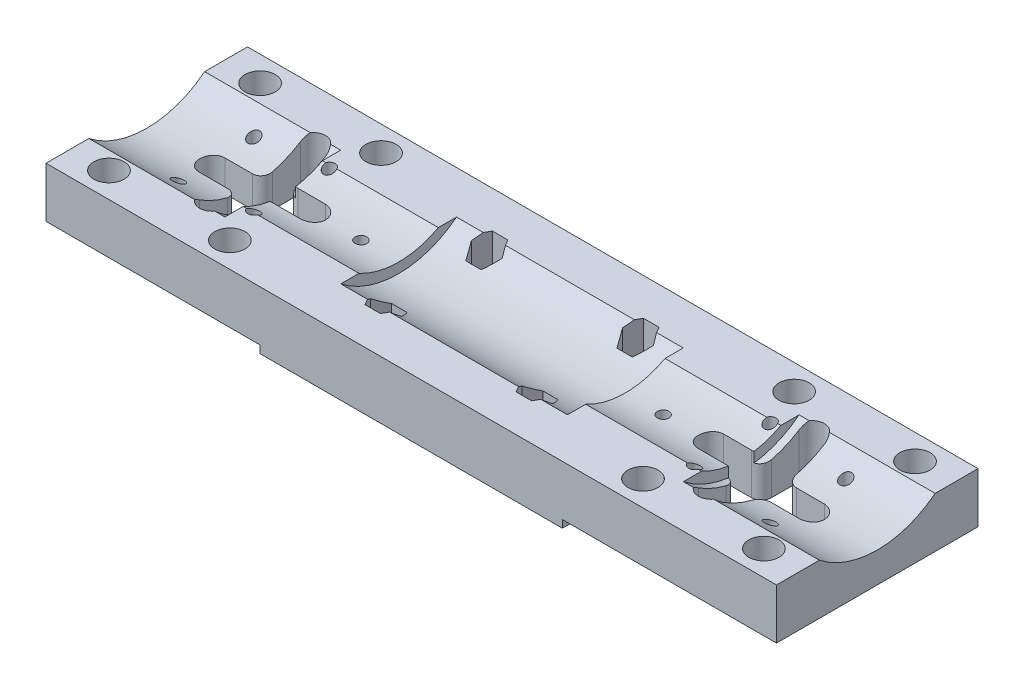
from build123d import *

# Parameters (mm, degrees)
EXTRUDE_1_DEPTH     = 145
SKETCH_2_R          = 3
CUT_EXTRUDE_1_DEPTH = 11
EXTRUDE_2_DEPTH     = 23
SKETCH_4_W          = 60
SKETCH_4_H          = 40
EXTRUDE_3_DEPTH     = 1.5
SKETCH_5_R          = 1.65
CUT_EXTRUDE_2_DEPTH = 12.5
CUT_EXTRUDE_3_DEPTH = 7
SKETCH_7_R          = 1.15
CUT_EXTRUDE_4_DEPTH = 11
CUT_EXTRUDE_5_DEPTH = 11.0000001
FILLET_1_R          = 2


with BuildPart() as part:
    # 草图1 → 凸台-拉伸1 (new body)
    with BuildSketch(Plane(origin=(0, 0, 0), x_dir=(0, 0, -1), z_dir=(1, 0, 0))):
        with BuildLine():
            Line((-20, 10), (-20, 0))
            Line((-20, 0), (20, 0))
            Line((20, 0), (20, 10))
            Line((20, 10), (11.489125293, 10))
            ThreePointArc((11.489125293, 10), (0, 6), (-11.489125293, 10))
            Line((-11.489125293, 10), (-20, 10))
        make_face()
    extrude(amount=EXTRUDE_1_DEPTH)

    # 草图2 → 切除-拉伸1 (cut, through all)
    with BuildSketch(Plane.XZ):
        with Locations((137.5, -15)):
            Circle(SKETCH_2_R)
        with Locations((113.5, -15)):
            Circle(SKETCH_2_R)
        with Locations((113.5, 15)):
            Circle(SKETCH_2_R)
        with Locations((137.5, 15)):
            Circle(SKETCH_2_R)
        with Locations((7.5, 15)):
            Circle(SKETCH_2_R)
        with Locations((31.5, 15)):
            Circle(SKETCH_2_R)
        with Locations((31.5, -15)):
            Circle(SKETCH_2_R)
        with Locations((7.5, -15)):
            Circle(SKETCH_2_R)
    extrude(amount=-CUT_EXTRUDE_1_DEPTH, mode=Mode.SUBTRACT)

    # 草图3 → 凸台-拉伸2 (add)
    with BuildSketch(Plane(origin=(27, 0, 0), x_dir=(0, 0, -1), z_dir=(1, 0, 0))):
        with BuildLine():
            Line((11.489125293, 10), (7.874007874, 10))
            ThreePointArc((7.874007874, 10), (0, 8), (-7.874007874, 10))
            Line((-7.874007874, 10), (-11.489125293, 10))
            ThreePointArc((-11.489125293, 10), (0, 6), (11.489125293, 10))
        make_face()
    extrude_2 = extrude(amount=EXTRUDE_2_DEPTH)

    # 镜向1: 凸台-拉伸2 across plane
    add(extrude_2.mirror(Plane(origin=(72.5, 0, 0), x_dir=(0, 0, 1), z_dir=(1, 0, 0))))

    # 草图4 → 凸台-拉伸3 (add)
    with BuildSketch(Plane.XZ):
        with Locations((72.5, 0)):
            Rectangle(SKETCH_4_W, SKETCH_4_H)
    extrude(amount=EXTRUDE_3_DEPTH)

    # 草图5 → 切除-拉伸2 (cut, through all)
    with BuildSketch(Plane.XZ.offset(1.5)):
        with Locations((57.5, 10)):
            Circle(SKETCH_5_R)
        with Locations((57.5, -10)):
            Circle(SKETCH_5_R)
        with Locations((87.5, -10)):
            Circle(SKETCH_5_R)
        with Locations((87.5, 10)):
            Circle(SKETCH_5_R)
    extrude(amount=-CUT_EXTRUDE_2_DEPTH, mode=Mode.SUBTRACT)

    # 草图6 → 切除-拉伸3 (cut)
    with BuildSketch(Plane(origin=(0, 10, 0), x_dir=(1, 0, 0), z_dir=(0, 1, 0))):
        Polygon((60.559956427, 10), (59.029978213, 12.65), (55.970021787, 12.65), (54.440043573, 10), (55.970021787, 7.35), (59.029978213, 7.35), align=None)
        Polygon((90.559956427, 10), (89.029978213, 12.65), (85.970021787, 12.65), (84.440043573, 10), (85.970021787, 7.35), (89.029978213, 7.35), align=None)
        Polygon((60.559956427, -10), (59.029978213, -7.35), (55.970021787, -7.35), (54.440043573, -10), (55.970021787, -12.65), (59.029978213, -12.65), align=None)
        Polygon((90.559956427, -10), (89.029978213, -7.35), (85.970021787, -7.35), (84.440043573, -10), (85.970021787, -12.65), (89.029978213, -12.65), align=None)
    extrude(amount=-CUT_EXTRUDE_3_DEPTH, mode=Mode.SUBTRACT)

    # 草图7 → 切除-拉伸4 (cut, through all)
    with BuildSketch(Plane.XZ):
        with Locations((131.25, -7.5)):
            Circle(SKETCH_7_R)
        with Locations((116.25, -7.5)):
            Circle(SKETCH_7_R)
        with Locations((116.25, 7.5)):
            Circle(SKETCH_7_R)
        with Locations((131.25, 7.5)):
            Circle(SKETCH_7_R)
        with Locations((13.75, 7.5)):
            Circle(SKETCH_7_R)
        with Locations((28.75, 7.5)):
            Circle(SKETCH_7_R)
        with Locations((28.75, -7.5)):
            Circle(SKETCH_7_R)
        with Locations((13.75, -7.5)):
            Circle(SKETCH_7_R)
        with Locations((102.5, 0)):
            Circle(SKETCH_7_R)
        with Locations((42.5, 0)):
            Circle(SKETCH_7_R)
    extrude(amount=-CUT_EXTRUDE_4_DEPTH, mode=Mode.SUBTRACT)

    # 草图8 → 切除-拉伸5 (cut, through all)
    with BuildSketch(Plane.XZ):
        with BuildLine():
            Line((132.008785565, -2.5), (124.508785565, -2.5))
            Line((124.508785565, -2.5), (124.508785565, -10))
            ThreePointArc((124.508785565, -10), (122.008785565, -12.5), (119.508785565, -10))
            Line((119.508785565, -10), (119.508785565, -2.5))
            Line((119.508785565, -2.5), (112.008785565, -2.5))
            ThreePointArc((112.008785565, -2.5), (109.508785565, 0), (112.008785565, 2.5))
            Line((112.008785565, 2.5), (119.508785565, 2.5))
            Line((119.508785565, 2.5), (119.508785565, 10))
            ThreePointArc((119.508785565, 10), (122.008785565, 12.5), (124.508785565, 10))
            Line((124.508785565, 10), (124.508785565, 2.5))
            Line((124.508785565, 2.5), (132.008785565, 2.5))
            ThreePointArc((132.008785565, 2.5), (134.508785565, 0), (132.008785565, -2.5))
        make_face()
        with BuildLine():
            Line((25.491214435, 2.5), (32.991214435, 2.5))
            ThreePointArc((32.991214435, 2.5), (35.491214435, 0), (32.991214435, -2.5))
            Line((32.991214435, -2.5), (25.491214435, -2.5))
            Line((25.491214435, -2.5), (25.491214435, -10))
            ThreePointArc((25.491214435, -10), (22.991214435, -12.5), (20.491214435, -10))
            Line((20.491214435, -10), (20.491214435, -2.5))
            Line((20.491214435, -2.5), (12.991214435, -2.5))
            ThreePointArc((12.991214435, -2.5), (10.491214435, 0), (12.991214435, 2.5))
            Line((12.991214435, 2.5), (20.491214435, 2.5))
            Line((20.491214435, 2.5), (20.491214435, 10))
            ThreePointArc((20.491214435, 10), (22.991214435, 12.5), (25.491214435, 10))
            Line((25.491214435, 10), (25.491214435, 2.5))
        make_face()
    extrude(amount=-CUT_EXTRUDE_5_DEPTH, mode=Mode.SUBTRACT)

    # 圆角1
    fillet_1_edges = [part.edges().sort_by_distance(p)[0] for p in [
        (124.508785565, 3.08484861, -2.5),
        (119.508785565, 3.08484861, -2.5),
        (119.508785565, 3.08484861, 2.5),
        (124.508785565, 3.08484861, 2.5),
        (20.491214435, 3.08484861, -2.5),
        (25.491214435, 3.08484861, -2.5),
        (25.491214435, 3.08484861, 2.5),
        (20.491214435, 3.08484861, 2.5),
    ]]
    fillet(fillet_1_edges, radius=FILLET_1_R)


solid = part.part
